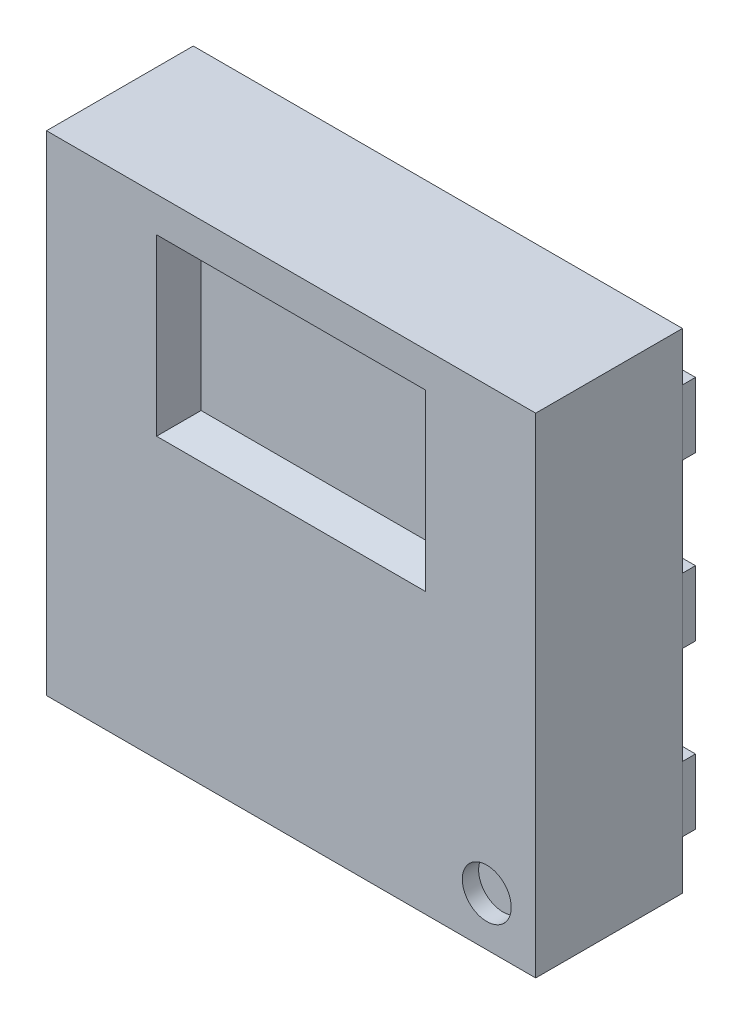
from build123d import *

# Parameters (mm, degrees)
SKETCH1_W             = 3
SKETCH1_H             = 3
BOSS_EXTRUDE1_DEPTH   = 0.9
SKETCH2_W             = 1.65
SKETCH2_H             = 1.07
CUT_EXTRUDE1_DEPTH    = 0.2
CUT_EXTRUDE1_TAPER    = 20
BOSS_EXTRUDE2_DEPTH   = 0.08
SKETCH4_W             = 0.4
SKETCH4_H             = 0.4
BOSS_EXTRUDE3_DEPTH   = 0.08
BOSS_EXTRUDE3_2_DEPTH = 0.08
BOSS_EXTRUDE3_3_DEPTH = 0.08
BOSS_EXTRUDE3_4_DEPTH = 0.08
BOSS_EXTRUDE3_5_DEPTH = 0.08
BOSS_EXTRUDE3_6_DEPTH = 0.08
SKETCH5_R             = 0.15
CUT_EXTRUDE2_DEPTH    = 0.1


with BuildPart() as part:
    # Sketch1 → Boss-Extrude1 (new body)
    with BuildSketch(Plane.XY):
        with Locations((1.5, 1.5)):
            Rectangle(SKETCH1_W, SKETCH1_H)
    extrude(amount=BOSS_EXTRUDE1_DEPTH)

    # Sketch2 → Cut-Extrude1 (cut)
    with BuildSketch(Plane.XY.offset(0.9)):
        with Locations((1.5, 2.25)):
            Rectangle(SKETCH2_W, SKETCH2_H)
    extrude(amount=-CUT_EXTRUDE1_DEPTH, taper=CUT_EXTRUDE1_TAPER, mode=Mode.SUBTRACT)

    # Sketch3 → Boss-Extrude2 (add)
    with BuildSketch(Plane(origin=(0, 0, 0), x_dir=(-1, 0, 0), z_dir=(0, 0, -1))):
        Polygon((-2.25, 0.582842712), (-1.967157288, 0.3), (-0.75, 0.3), (-0.75, 2.7), (-2.25, 2.7), align=None)
    extrude(amount=BOSS_EXTRUDE2_DEPTH)

    # Sketch5 → Cut-Extrude2 (cut)
    with BuildSketch(Plane.XY.offset(0.9)):
        with Locations((2.7, 0.3)):
            Circle(SKETCH5_R)
    extrude(amount=-CUT_EXTRUDE2_DEPTH, mode=Mode.SUBTRACT)


with BuildPart() as body_2:
    # Sketch4 → Boss-Extrude3 (new body)
    with BuildSketch(Plane(origin=(0, 0, 0), x_dir=(-1, 0, 0), z_dir=(0, 0, -1))):
        with Locations((-2.8, 0.5)):
            Rectangle(SKETCH4_W, SKETCH4_H)
    extrude(amount=BOSS_EXTRUDE3_DEPTH)


with BuildPart() as body_3:
    # Sketch4 → Boss-Extrude3 2 (new body)
    with BuildSketch(Plane(origin=(0, 0, 0), x_dir=(-1, 0, 0), z_dir=(0, 0, -1))):
        with Locations((-2.8, 1.5)):
            Rectangle(SKETCH4_W, SKETCH4_H)
    extrude(amount=BOSS_EXTRUDE3_2_DEPTH)


with BuildPart() as body_4:
    # Sketch4 → Boss-Extrude3 3 (new body)
    with BuildSketch(Plane(origin=(0, 0, 0), x_dir=(-1, 0, 0), z_dir=(0, 0, -1))):
        with Locations((-2.8, 2.5)):
            Rectangle(SKETCH4_W, SKETCH4_H)
    extrude(amount=BOSS_EXTRUDE3_3_DEPTH)


with BuildPart() as body_5:
    # Sketch4 → Boss-Extrude3 4 (new body)
    with BuildSketch(Plane(origin=(0, 0, 0), x_dir=(-1, 0, 0), z_dir=(0, 0, -1))):
        with Locations((-0.2, 2.5)):
            Rectangle(SKETCH4_W, SKETCH4_H)
    extrude(amount=BOSS_EXTRUDE3_4_DEPTH)


with BuildPart() as body_6:
    # Sketch4 → Boss-Extrude3 5 (new body)
    with BuildSketch(Plane(origin=(0, 0, 0), x_dir=(-1, 0, 0), z_dir=(0, 0, -1))):
        with Locations((-0.2, 1.5)):
            Rectangle(SKETCH4_W, SKETCH4_H)
    extrude(amount=BOSS_EXTRUDE3_5_DEPTH)


with BuildPart() as body_7:
    # Sketch4 → Boss-Extrude3 6 (new body)
    with BuildSketch(Plane(origin=(0, 0, 0), x_dir=(-1, 0, 0), z_dir=(0, 0, -1))):
        with Locations((-0.2, 0.5)):
            Rectangle(SKETCH4_W, SKETCH4_H)
    extrude(amount=BOSS_EXTRUDE3_6_DEPTH)


solid = Compound([part.part, body_2.part, body_3.part, body_4.part, body_5.part, body_6.part, body_7.part])
